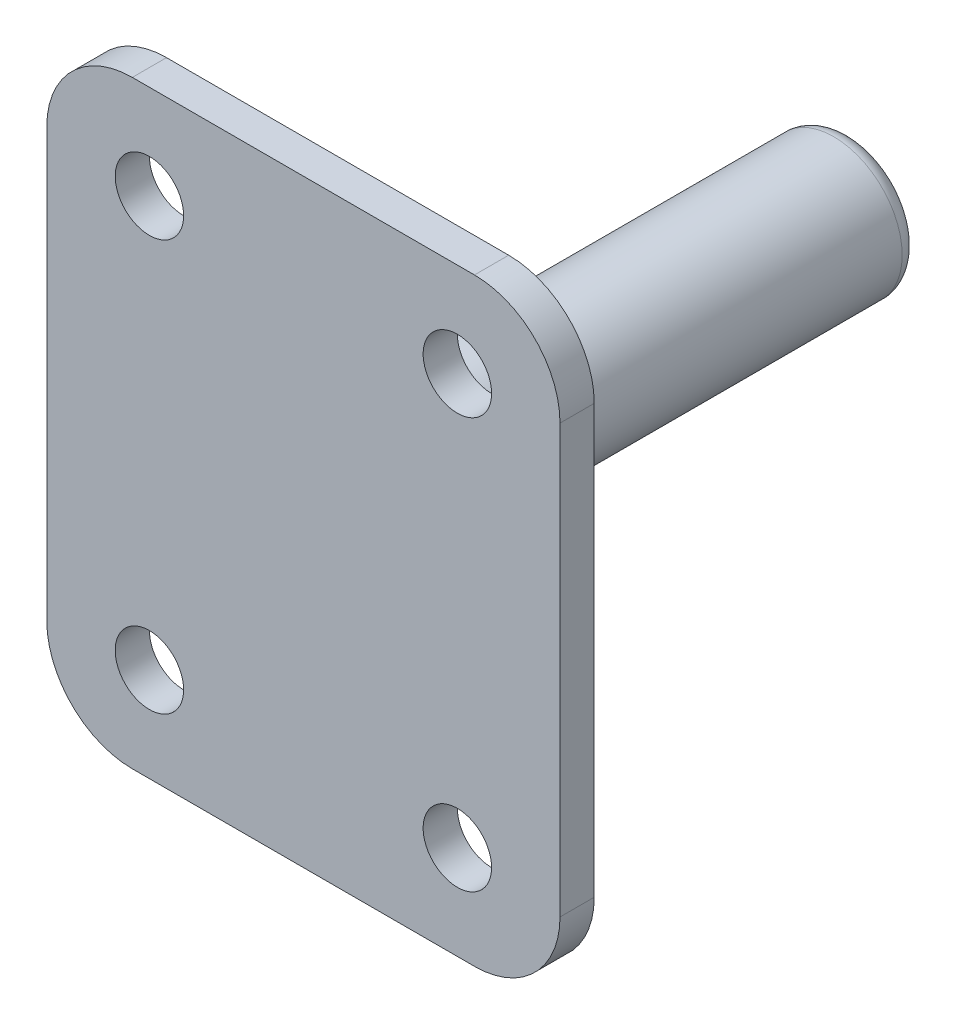
from build123d import *

# Parameters (mm, degrees)
SKETCH2_W           = 30
SKETCH2_H           = 35
BOSS_EXTRUDE1_DEPTH = 2
FILLET1_R           = 5
SKETCH3_R           = 2
CUT_EXTRUDE1_DEPTH  = 10
SKETCH6_R           = 4
BOSS_EXTRUDE2_DEPTH = 30
FILLET2_R           = 1


with BuildPart() as part:
    # Sketch2 → Boss-Extrude1 (new body)
    with BuildSketch(Plane.XY):
        with Locations((15, -17.5)):
            Rectangle(SKETCH2_W, SKETCH2_H)
    extrude(amount=BOSS_EXTRUDE1_DEPTH)

    # Fillet1
    fillet1_edges = [part.edges().sort_by_distance(p)[0] for p in [
        (0, 0, 1),
        (30, 0, 1),
        (30, -35, 1),
        (0, -35, 1),
    ]]
    fillet(fillet1_edges, radius=FILLET1_R)

    # Sketch3 → Cut-Extrude1 (cut)
    with BuildSketch(Plane.XY.offset(2)):
        with Locations((6, -5.5)):
            Circle(SKETCH3_R)
        with Locations((24, -5.5)):
            Circle(SKETCH3_R)
        with Locations((6, -29.5)):
            Circle(SKETCH3_R)
        with Locations((24, -29.5)):
            Circle(SKETCH3_R)
    extrude(amount=-CUT_EXTRUDE1_DEPTH, mode=Mode.SUBTRACT)

    # Sketch6 → Boss-Extrude2 (add)
    with BuildSketch(Plane(origin=(0, 0, 0), x_dir=(-1, 0, 0), z_dir=(0, 0, -1))):
        with Locations((-15, -17.5)):
            Circle(SKETCH6_R)
    extrude(amount=BOSS_EXTRUDE2_DEPTH)

    # Fillet2
    fillet2_edges = [part.edges().sort_by_distance(p)[0] for p in [
        (19, -17.5, -30),
    ]]
    fillet(fillet2_edges, radius=FILLET2_R)


solid = part.part
